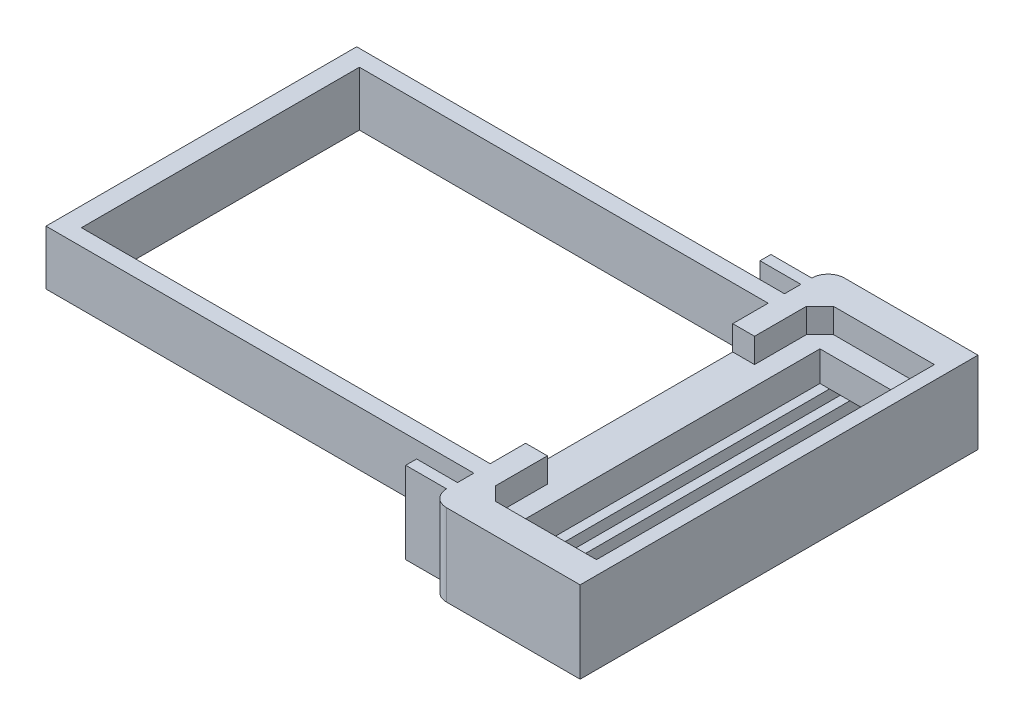
from build123d import *

# Parameters (mm, degrees)
SKETCH_1_W      = 15
SKETCH_1_H      = 10.2
SKETCH_1_W_2    = 3.5
SKETCH_1_H_2    = 11
EXTRUDE_1_DEPTH = 1.1
EXTRUDE_2_DEPTH = 0.9
SKETCH_3_W      = 0.4
SKETCH_3_H      = 12
EXTRUDE_3_DEPTH = 1
EXTRUDE_4_DEPTH = 1.5


with BuildPart() as part:
    # 草图1 → 凸台-拉伸1 (new body)
    with BuildSketch(Plane(origin=(0, 0, 0), x_dir=(1, 0, 0), z_dir=(0, 1, 0))):
        with BuildLine():
            Line((-0.7, 0.6), (-0.7, -10.8))
            Line((-0.7, -10.8), (15, -10.8))
            Line((15, -10.8), (15, -11.8))
            ThreePointArc((15, -11.8), (15.175735931, -12.224264069), (15.6, -12.4))
            Line((15.6, -12.4), (20.5, -12.4))
            Line((20.5, -12.4), (20.5, 2.2))
            Line((20.5, 2.2), (15.6, 2.2))
            ThreePointArc((15.6, 2.2), (15.175735931, 2.024264069), (15, 1.6))
            Line((15, 1.6), (15, 0.6))
            Line((15, 0.6), (-0.7, 0.6))
        make_face()
        with Locations((7.5, -5.1)):
            Rectangle(SKETCH_1_W, SKETCH_1_H, mode=Mode.SUBTRACT)
        with Locations((18.25, -5.1)):
            Rectangle(SKETCH_1_W_2, SKETCH_1_H_2, mode=Mode.SUBTRACT)
    extrude(amount=EXTRUDE_1_DEPTH)

    # 草图2 → 凸台-拉伸2 (add)
    with BuildSketch(Plane(origin=(0, 1.1, 0), x_dir=(1, 0, 0), z_dir=(0, 1, 0))):
        with BuildLine():
            Line((15, -10.8), (-0.7, -10.8))
            Line((-0.7, -10.8), (-0.7, 0.6))
            Line((-0.7, 0.6), (15, 0.6))
            Line((15, 0.6), (15, 1.6))
            ThreePointArc((15, 1.6), (15.175735931, 2.024264069), (15.6, 2.2))
            Line((15.6, 2.2), (20.5, 2.2))
            Line((20.5, 2.2), (20.5, -12.4))
            Line((20.5, -12.4), (15.6, -12.4))
            ThreePointArc((15.6, -12.4), (15.175735931, -12.224264069), (15, -11.8))
            Line((15, -11.8), (15, -10.8))
        make_face()
        Polygon((15, 0), (0, 0), (0, -10.2), (15, -10.2), (15, -8.9), (15.8, -8.9), (15.8, -10.8), (16.3, -11.3), (20, -11.3), (20, 1.1), (16.3, 1.1), (15.8, 0.6), (15.8, -1.3), (15, -1.3), align=None, mode=Mode.SUBTRACT)
    extrude(amount=EXTRUDE_2_DEPTH)

    # 草图3 → 凸台-拉伸3 (add)
    with BuildSketch(Plane.XZ):
        with BuildLine():
            Line((20.5, -2.2), (15.6, -2.2))
            ThreePointArc((15.6, -2.2), (15.175735931, -2.024264069), (15, -1.6))
            Line((15, -1.6), (15, 11.8))
            ThreePointArc((15, 11.8), (15.175735931, 12.224264069), (15.6, 12.4))
            Line((15.6, 12.4), (20.5, 12.4))
            Line((20.5, 12.4), (20.5, -2.2))
        make_face()
        with Locations((17.05, 5.1)):
            Rectangle(SKETCH_3_W, SKETCH_3_H, mode=Mode.SUBTRACT)
        with Locations((17.8, 5.1)):
            Rectangle(SKETCH_3_W, SKETCH_3_H, mode=Mode.SUBTRACT)
        with Locations((18.55, 5.1)):
            Rectangle(SKETCH_3_W, SKETCH_3_H, mode=Mode.SUBTRACT)
        with Locations((19.3, 5.1)):
            Rectangle(SKETCH_3_W, SKETCH_3_H, mode=Mode.SUBTRACT)
    extrude(amount=EXTRUDE_3_DEPTH)

    # 草图4 → 凸台-拉伸4 (add)
    with BuildSketch(Plane.ZY.offset(-15)):
        Polygon((11.8, 2), (11.8, -1), (-1.6, -1), (-1.6, 2), (-1.2, 2), (-1.2, -0.6), (11.4, -0.6), (11.4, 2), align=None)
    extrude(amount=EXTRUDE_4_DEPTH)


solid = part.part
